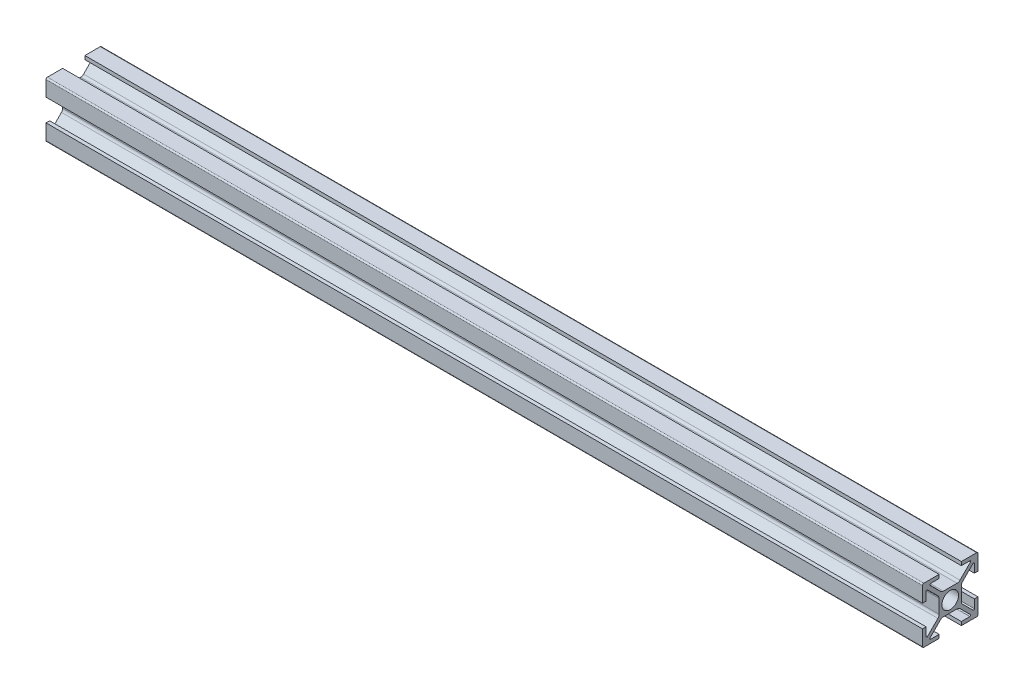
from build123d import *

# Parameters (mm, degrees)
SKETCH1_R                                   = 3
QUADRADO_PF20_01_PERFIL_2020_B_SICO_1_DEPTH = 315.6


with BuildPart() as part:
    # Sketch1 → Quadrado PF20-01 - PERFIL 2020 BÁSICO(1) (new body)
    with BuildSketch(Plane.YZ):
        with BuildLine():
            Line((8.187867966, -7.26862915), (4.439339828, -3.520101013))
            ThreePointArc((4.439339828, -3.520101013), (4.114180701, -3.033465989), (4, -2.459440841))
            Line((4, -2.459440841), (4, 2.459440841))
            ThreePointArc((4, 2.459440841), (4.114180701, 3.033465989), (4.439339828, 3.520101013))
            Line((4.439339828, 3.520101013), (8.187867966, 7.26862915))
            ThreePointArc((8.187867966, 7.26862915), (8.51480503, 7.333660975), (8.7, 7.056497116))
            Line((8.7, 7.056497116), (8.7, 4))
            Line((8.7, 4), (10, 4))
            Line((10, 4), (10, 9.5))
            ThreePointArc((10, 9.5), (9.853553391, 9.853553391), (9.5, 10))
            Line((9.5, 10), (4, 10))
            Line((4, 10), (4, 8.7))
            Line((4, 8.7), (7.056497116, 8.7))
            ThreePointArc((7.056497116, 8.7), (7.333660975, 8.51480503), (7.26862915, 8.187867966))
            Line((7.26862915, 8.187867966), (3.520101013, 4.439339828))
            ThreePointArc((3.520101013, 4.439339828), (3.033465989, 4.114180701), (2.459440841, 4))
            Line((2.459440841, 4), (-2.459440841, 4))
            ThreePointArc((-2.459440841, 4), (-3.033465989, 4.114180701), (-3.520101013, 4.439339828))
            Line((-3.520101013, 4.439339828), (-7.26862915, 8.187867966))
            ThreePointArc((-7.26862915, 8.187867966), (-7.333660975, 8.51480503), (-7.056497116, 8.7))
            Line((-7.056497116, 8.7), (-4, 8.7))
            Line((-4, 8.7), (-4, 10))
            Line((-4, 10), (-9.5, 10))
            ThreePointArc((-9.5, 10), (-9.853553391, 9.853553391), (-10, 9.5))
            Line((-10, 9.5), (-10, 4))
            Line((-10, 4), (-8.7, 4))
            Line((-8.7, 4), (-8.7, 7.056497116))
            ThreePointArc((-8.7, 7.056497116), (-8.51480503, 7.333660975), (-8.187867966, 7.26862915))
            Line((-8.187867966, 7.26862915), (-4.439339828, 3.520101013))
            ThreePointArc((-4.439339828, 3.520101013), (-4.114180701, 3.033465989), (-4, 2.459440841))
            Line((-4, 2.459440841), (-4, -2.459440841))
            ThreePointArc((-4, -2.459440841), (-4.114180701, -3.033465989), (-4.439339828, -3.520101013))
            Line((-4.439339828, -3.520101013), (-8.187867966, -7.26862915))
            ThreePointArc((-8.187867966, -7.26862915), (-8.51480503, -7.333660975), (-8.7, -7.056497116))
            Line((-8.7, -7.056497116), (-8.7, -4))
            Line((-8.7, -4), (-10, -4))
            Line((-10, -4), (-10, -9.5))
            ThreePointArc((-10, -9.5), (-9.853553391, -9.853553391), (-9.5, -10))
            Line((-9.5, -10), (-4, -10))
            Line((-4, -10), (-4, -8.7))
            Line((-4, -8.7), (-7.056497116, -8.7))
            ThreePointArc((-7.056497116, -8.7), (-7.333660975, -8.51480503), (-7.26862915, -8.187867966))
            Line((-7.26862915, -8.187867966), (-3.520101013, -4.439339828))
            ThreePointArc((-3.520101013, -4.439339828), (-3.033465989, -4.114180701), (-2.459440841, -4))
            Line((-2.459440841, -4), (2.459440841, -4))
            ThreePointArc((2.459440841, -4), (3.033465989, -4.114180701), (3.520101013, -4.439339828))
            Line((3.520101013, -4.439339828), (7.26862915, -8.187867966))
            ThreePointArc((7.26862915, -8.187867966), (7.333660975, -8.51480503), (7.056497116, -8.7))
            Line((7.056497116, -8.7), (4, -8.7))
            Line((4, -8.7), (4, -10))
            Line((4, -10), (9.5, -10))
            ThreePointArc((9.5, -10), (9.853553391, -9.853553391), (10, -9.5))
            Line((10, -9.5), (10, -4))
            Line((10, -4), (8.7, -4))
            Line((8.7, -4), (8.7, -7.056497116))
            ThreePointArc((8.7, -7.056497116), (8.51480503, -7.333660975), (8.187867966, -7.26862915))
        make_face()
        Circle(SKETCH1_R, mode=Mode.SUBTRACT)
    extrude(amount=QUADRADO_PF20_01_PERFIL_2020_B_SICO_1_DEPTH)


solid = part.part
